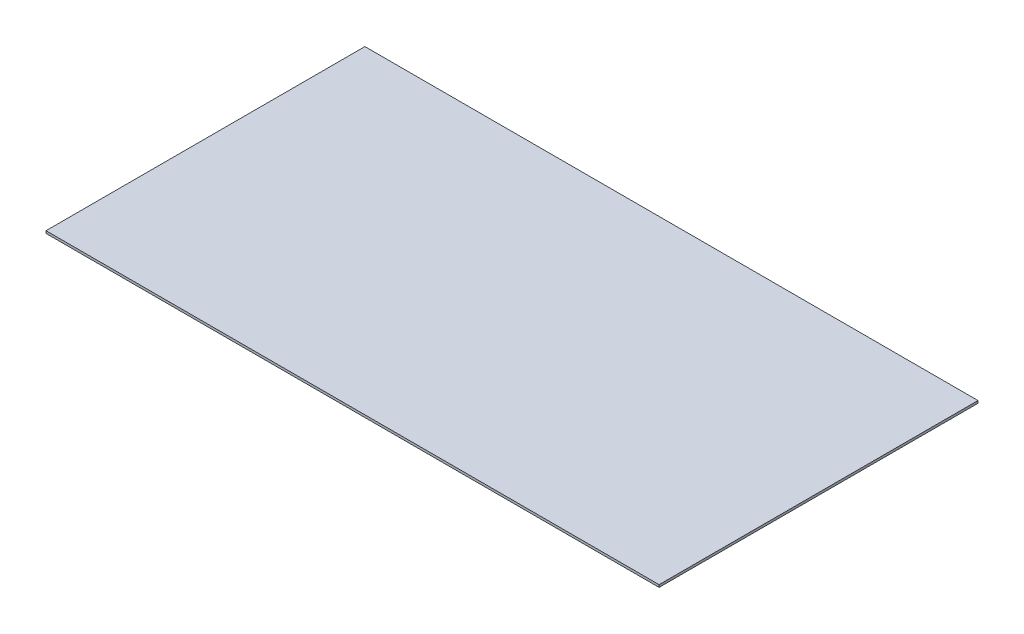
from build123d import *

# Parameters (mm, degrees)
SKETCH1_W      = 76.9
SKETCH1_H      = 40
EXTRUDE1_DEPTH = 0.3


with BuildPart() as part:
    # Sketch1 → Extrude1 (new body)
    with BuildSketch(Plane(origin=(0, 0, 0), x_dir=(1, 0, 0), z_dir=(0, 1, 0))):
        Rectangle(SKETCH1_W, SKETCH1_H)
    extrude(amount=EXTRUDE1_DEPTH)


solid = part.part
